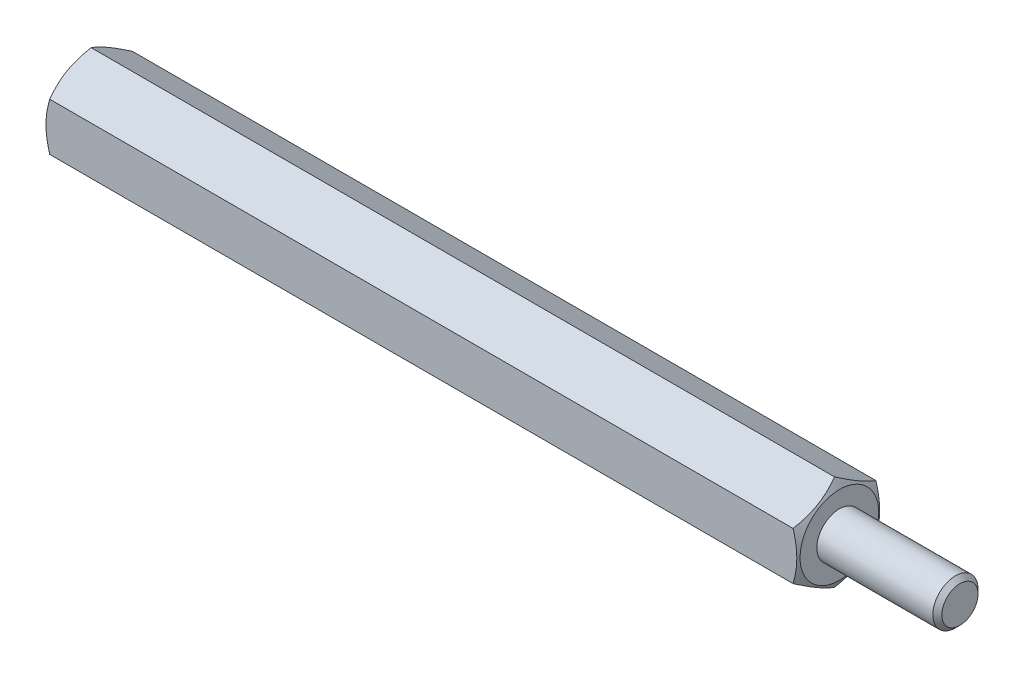
from build123d import *

# Parameters (mm, degrees)
BOSS_EXTRUDE1_DEPTH = 50
SKETCH2_R           = 1.5
BOSS_EXTRUDE2_DEPTH = 8
SKETCH3_R           = 1.5
CUT_EXTRUDE1_DEPTH  = 10
CHAMFER1_SIZE       = 0.3


with BuildPart() as part:
    # Sketch1 → Boss-Extrude1 (new body)
    with BuildSketch(Plane(origin=(0, 0, 0), x_dir=(0, 0, -1), z_dir=(1, 0, 0))):
        Polygon((0, 3.175426481), (-2.75, 1.58771324), (-2.75, -1.58771324), (0, -3.175426481), (2.75, -1.58771324), (2.75, 1.58771324), align=None)
    extrude(amount=BOSS_EXTRUDE1_DEPTH)

    # Sketch2 → Boss-Extrude2 (add)
    with BuildSketch(Plane(origin=(50, 0, 0), x_dir=(0, 0, -1), z_dir=(1, 0, 0))):
        Circle(SKETCH2_R)
    extrude(amount=BOSS_EXTRUDE2_DEPTH)

    # Sketch3 → Cut-Extrude1 (cut)
    with BuildSketch(Plane.ZY):
        Circle(SKETCH3_R)
    extrude(amount=-CUT_EXTRUDE1_DEPTH, mode=Mode.SUBTRACT)

    # Sketch4 → Cut-Revolve1 (revolve, cut)
    with BuildSketch(Plane(origin=(0, 0, 0), x_dir=(1, 0, 0), z_dir=(0, 1, 0))):
        Polygon((0, 10.219809024), (4.392081913, 10.219809024), (0, 2.6125), align=None)
        Polygon((50, 2.6125), (50, 10.219809024), (45.607918087, 10.219809024), align=None)
    revolve(axis=Axis((0, 0, 0), (-1, 0, 0)), mode=Mode.SUBTRACT)

    # Chamfer1
    chamfer1_edges = [part.edges().sort_by_distance(p)[0] for p in [
        (58, 0, 1.5),
    ]]
    chamfer(chamfer1_edges, length=CHAMFER1_SIZE)


solid = part.part
